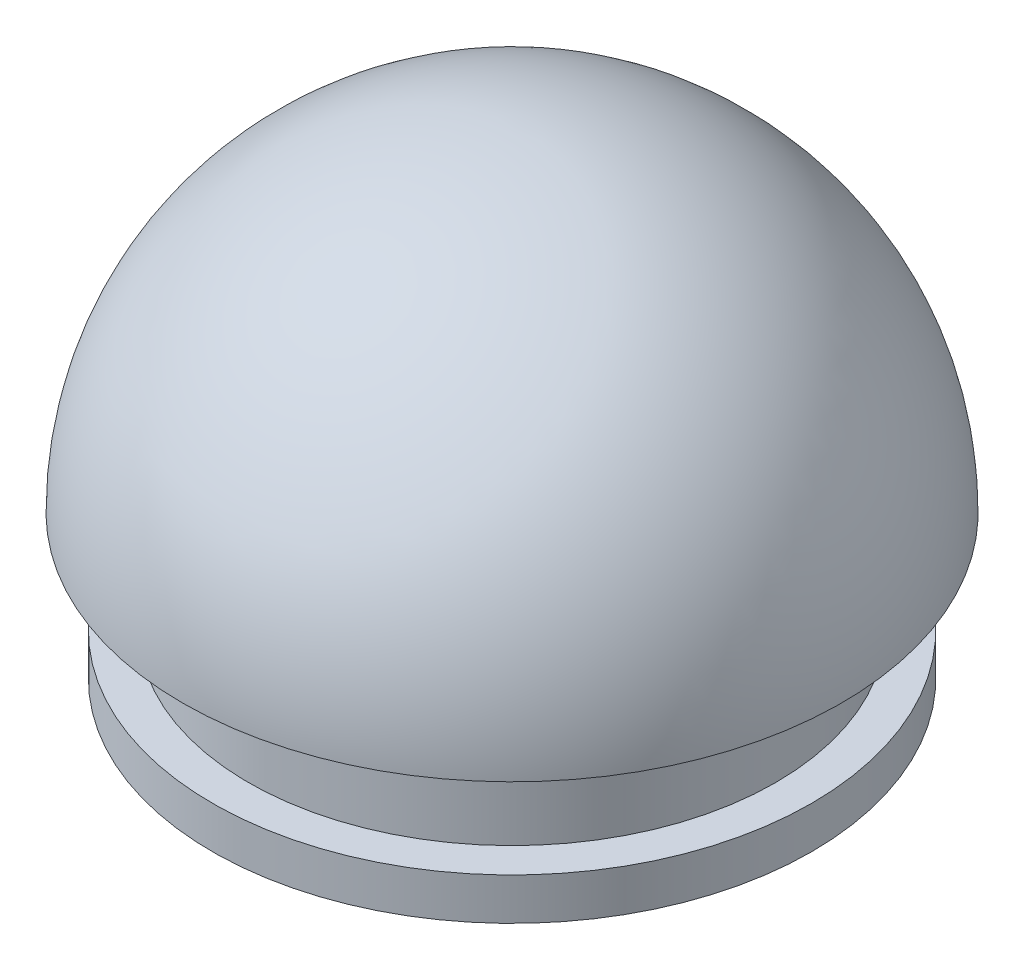
from build123d import *

# Parameters (mm, degrees)
REVOLVE1_ANGLE      = 180
SKETCH3_R           = 25.457715114
BOSS_EXTRUDE1_DEPTH = 5
SKETCH4_R           = 22
BOSS_EXTRUDE2_DEPTH = 12
SKETCH5_R           = 25
BOSS_EXTRUDE3_DEPTH = 3.5
SKETCH6_R           = 19.5
CUT_EXTRUDE1_DEPTH  = 17


with BuildPart() as part:
    # Sketch1 → Revolve1 (revolve)
    with BuildSketch(Plane(origin=(0, 0, 0), x_dir=(1, 0, 0), z_dir=(0, 1, 0))):
        with BuildLine():
            Line((-0.996315138, 27.481946004), (0.996315138, -27.481946004))
            ThreePointArc((0.996315138, -27.481946004), (27.481946004, 0.996315138), (-0.996315138, 27.481946004))
        make_face()
    revolve(axis=Axis((-0.996315138, 0, -27.481946004), (0.036229641, 0, 0.999343491)), revolution_arc=REVOLVE1_ANGLE)

    # Sketch2 → Cut-Revolve1 (revolve, cut)
    with BuildSketch(Plane.XZ):
        with BuildLine():
            Line((0, 25), (0, -25))
            ThreePointArc((0, -25), (25, 0), (0, 25))
        make_face()
    revolve(axis=Axis((0, 0, 25), (0, 0, -1)), mode=Mode.SUBTRACT)

    # Sketch3 → Boss-Extrude1 (add)
    with BuildSketch(Plane.XZ):
        Circle(SKETCH3_R)
    extrude(amount=-BOSS_EXTRUDE1_DEPTH)

    # Sketch4 → Boss-Extrude2 (add)
    with BuildSketch(Plane.XZ):
        Circle(SKETCH4_R)
    extrude(amount=BOSS_EXTRUDE2_DEPTH)

    # Sketch5 → Boss-Extrude3 (add)
    with BuildSketch(Plane.XZ.offset(12)):
        Circle(SKETCH5_R)
    extrude(amount=-BOSS_EXTRUDE3_DEPTH)

    # Sketch6 → Cut-Extrude1 (cut)
    with BuildSketch(Plane.XZ.offset(12)):
        Circle(SKETCH6_R)
    extrude(amount=-CUT_EXTRUDE1_DEPTH, mode=Mode.SUBTRACT)


solid = part.part
